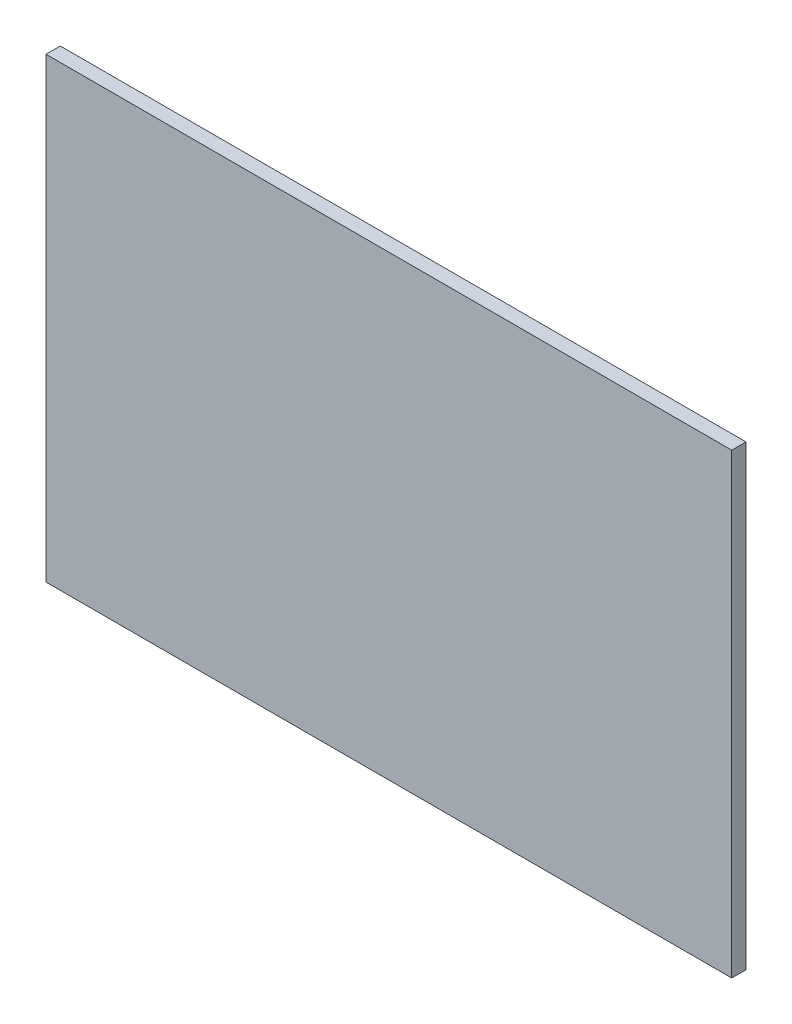
from build123d import *

# Parameters (mm, degrees)
SKETCH1_W           = 304.8
SKETCH1_H           = 203.2
BOSS_EXTRUDE1_DEPTH = 6.35


with BuildPart() as part:
    # Sketch1 → Boss-Extrude1 (new body)
    with BuildSketch(Plane.XY):
        with Locations((152.4, 101.6)):
            Rectangle(SKETCH1_W, SKETCH1_H)
    extrude(amount=BOSS_EXTRUDE1_DEPTH)


solid = part.part
